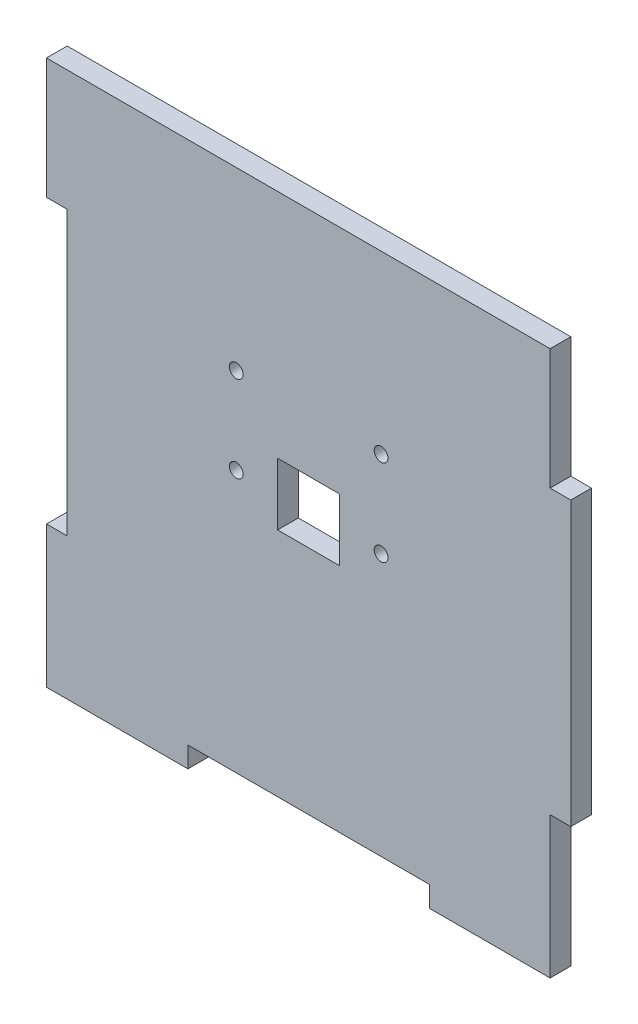
from build123d import *

# Parameters (mm, degrees)
BOSS_EXTRUDE1_DEPTH = 3
SKETCH2_R           = 1
SKETCH2_W           = 9
SKETCH2_H           = 9
CUT_EXTRUDE1_DEPTH  = 3


with BuildPart() as part:
    # Sketch1 → Boss-Extrude1 (new body)
    with BuildSketch(Plane.XY):
        Polygon((-35, 38), (-17.5, 38), (17.5, 38), (35, 38), (35, 20.5), (38, 20.5), (38, -20.5), (35, -20.5), (35, -38), (35, -41), (17.5, -41), (17.5, -38), (-17.5, -38), (-17.5, -41), (-35, -41), (-38, -41), (-38, -38), (-38, -20.5), (-35, -20.5), (-35, 20.5), (-38, 20.5), (-38, 38), align=None)
    extrude(amount=BOSS_EXTRUDE1_DEPTH)

    # Sketch2 → Cut-Extrude1 (cut)
    with BuildSketch(Plane.XY.offset(3)):
        with Locations((-10.5, 12.5)):
            Circle(SKETCH2_R)
        with Locations((-10.5, 0)):
            Circle(SKETCH2_R)
        with Locations((10.5, 12.5)):
            Circle(SKETCH2_R)
        with Locations((10.5, 0)):
            Circle(SKETCH2_R)
        Rectangle(SKETCH2_W, SKETCH2_H)
    extrude(amount=-CUT_EXTRUDE1_DEPTH, mode=Mode.SUBTRACT)


solid = part.part
